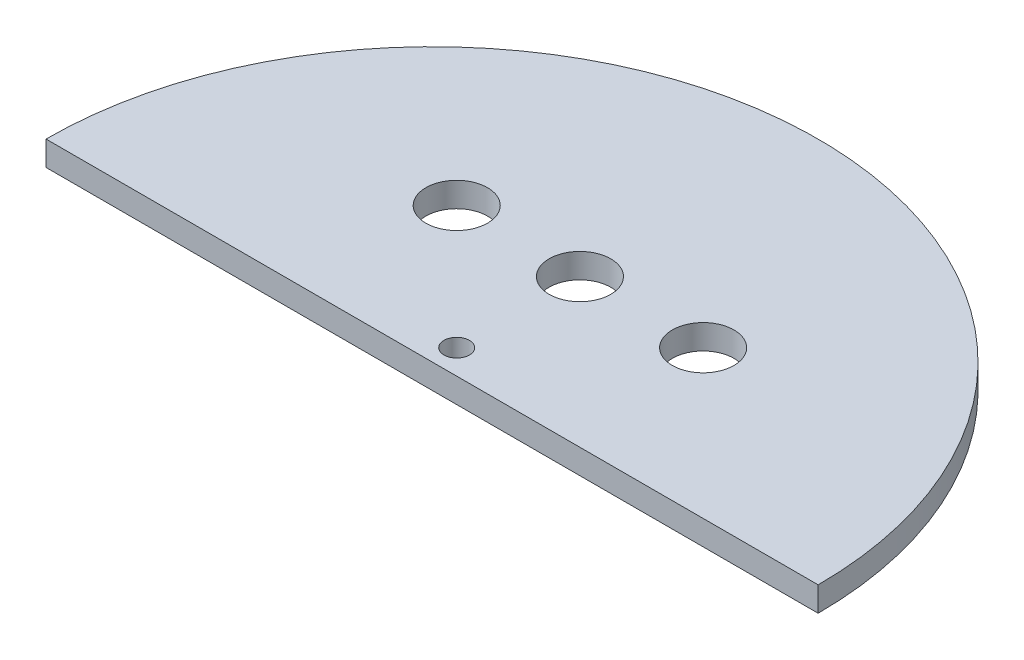
from build123d import *

# Parameters (mm, degrees)
SKETCH1_R           = 1.55
BOSS_EXTRUDE1_DEPTH = 3
SKETCH2_R           = 3.75
CUT_EXTRUDE1_DEPTH  = 3


with BuildPart() as part:
    # Sketch1 → Boss-Extrude1 (new body)
    with BuildSketch(Plane(origin=(0, 0, 0), x_dir=(1, 0, 0), z_dir=(0, 1, 0))):
        with BuildLine():
            Line((0, 0), (94, 0))
            ThreePointArc((94, 0), (47, 47), (0, 0))
        make_face()
        with Locations((47, 3)):
            Circle(SKETCH1_R, mode=Mode.SUBTRACT)
    extrude(amount=BOSS_EXTRUDE1_DEPTH)

    # Sketch2 → Cut-Extrude1 (cut)
    with BuildSketch(Plane(origin=(0, 3, 0), x_dir=(1, 0, 0), z_dir=(0, 1, 0))):
        with Locations((47, 18)):
            Circle(SKETCH2_R)
        with Locations((32, 18)):
            Circle(SKETCH2_R)
        with Locations((62, 18)):
            Circle(SKETCH2_R)
    extrude(amount=-CUT_EXTRUDE1_DEPTH, mode=Mode.SUBTRACT)


solid = part.part
